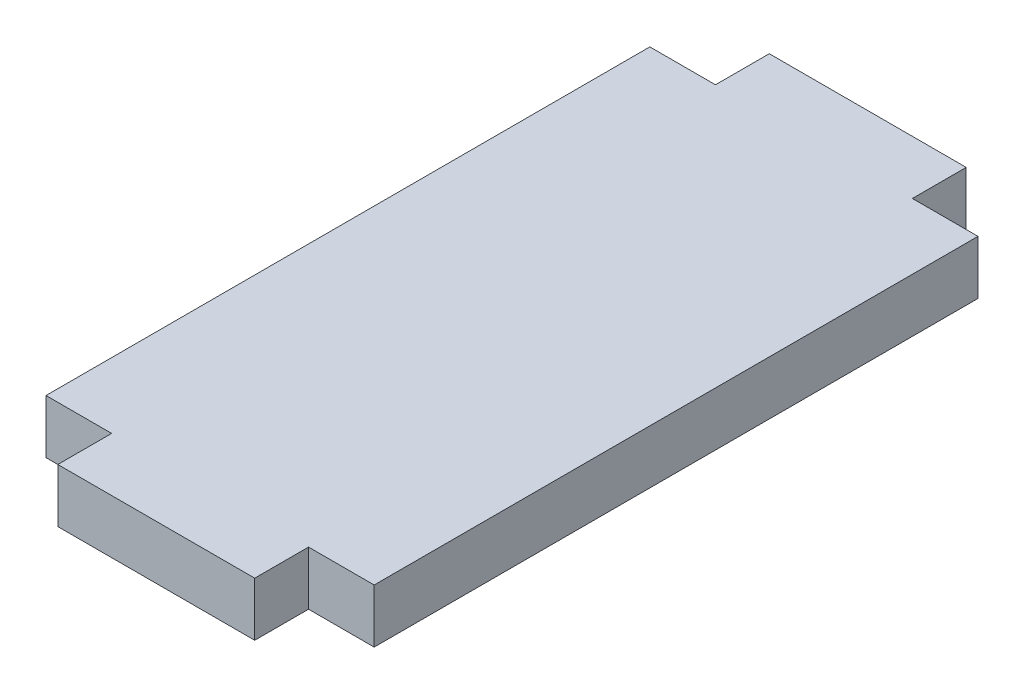
from build123d import *

# Parameters (mm, degrees)
BOSS_EXTRUDE1_DEPTH = 4.1


with BuildPart() as part:
    # Sketch1 → Boss-Extrude1 (new body)
    with BuildSketch(Plane(origin=(0, 0, 0), x_dir=(1, 0, 0), z_dir=(0, 1, 0))):
        Polygon((-12.5, -23), (-12.5, 23), (-7.5, 23), (-7.5, 27.1), (7.5, 27.1), (7.5, 23), (12.5, 23), (12.5, -23), (7.5, -23), (7.5, -27.1), (-7.5, -27.1), (-7.5, -23), align=None)
    extrude(amount=BOSS_EXTRUDE1_DEPTH)


solid = part.part
